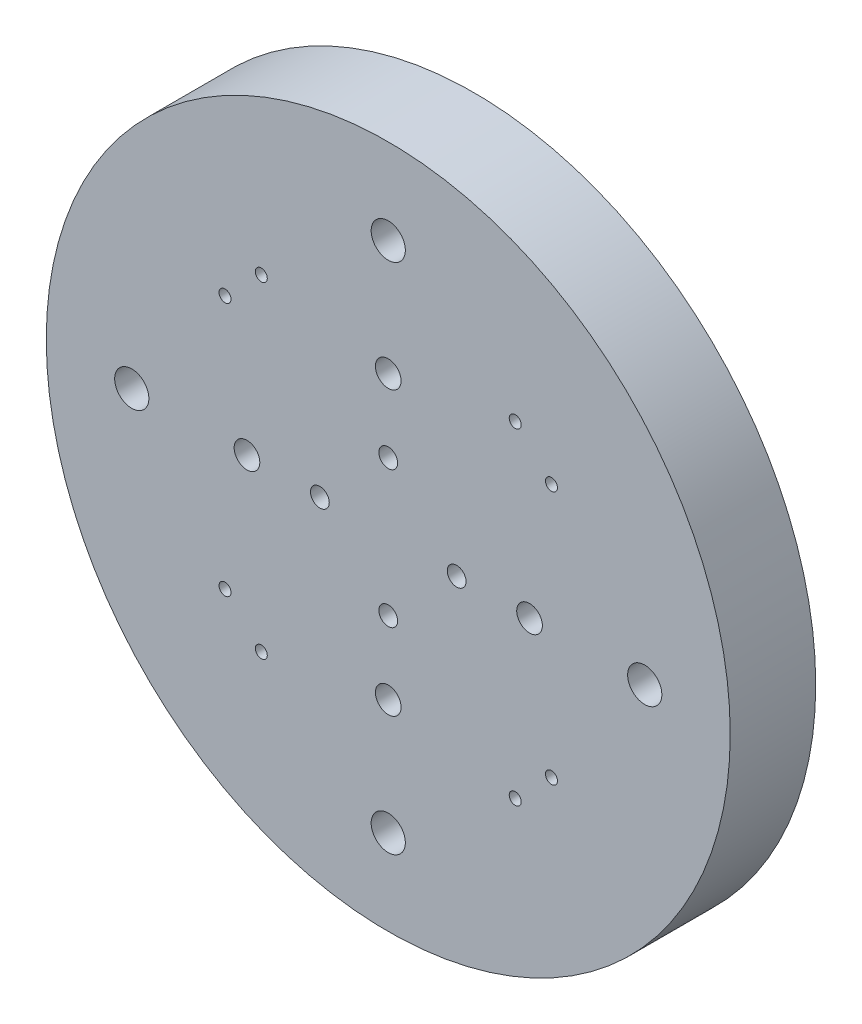
from build123d import *

# Parameters (mm, degrees)
SKETCH1_R                      = 40
BOSS_EXTRUDE1_DEPTH            = 10
F_4_0_4_DIAMETER_HOLE1_D       = 4
F_4_0_4_DIAMETER_HOLE1_DEPTH   = 10
F_4_0_4_DIAMETER_HOLE1_TIP     = 1.201721238
F_2_2_2_2_DIAMETER_HOLE1_D     = 2.2
F_2_2_2_2_DIAMETER_HOLE1_DEPTH = 10
F_2_2_2_2_DIAMETER_HOLE1_TIP   = 0.660946681
F_3_0_3_DIAMETER_HOLE4_D       = 3
F_3_0_3_DIAMETER_HOLE4_DEPTH   = 10
F_3_0_3_DIAMETER_HOLE4_TIP     = 0.901290929
F_1_4_1_4_DIAMETER_HOLE1_D     = 1.4
CIRPATTERN1_COUNT              = 4


with BuildPart() as part:
    # Sketch1 → Boss-Extrude1 (new body)
    with BuildSketch(Plane.XY):
        Circle(SKETCH1_R)
    extrude(amount=BOSS_EXTRUDE1_DEPTH)

    # Ø4.0 (4) Diameter Hole1
    with Locations(Plane.XY.offset(10)):
        with Locations((0, 30), (30, 0), (-30, 0), (0, -30)):
            Hole(F_4_0_4_DIAMETER_HOLE1_D / 2, depth=F_4_0_4_DIAMETER_HOLE1_DEPTH)
            with Locations((0, 0, -(F_4_0_4_DIAMETER_HOLE1_DEPTH + F_4_0_4_DIAMETER_HOLE1_TIP / 2))):  # 118° drill point
                Cone(0, F_4_0_4_DIAMETER_HOLE1_D / 2, F_4_0_4_DIAMETER_HOLE1_TIP, mode=Mode.SUBTRACT)

    # Ø2.2 (2.2) Diameter Hole1
    with Locations(Plane.XY.offset(10)):
        with Locations((0, 8), (0, -8), (-8, 0), (8, 0)):
            Hole(F_2_2_2_2_DIAMETER_HOLE1_D / 2, depth=F_2_2_2_2_DIAMETER_HOLE1_DEPTH)
            with Locations((0, 0, -(F_2_2_2_2_DIAMETER_HOLE1_DEPTH + F_2_2_2_2_DIAMETER_HOLE1_TIP / 2))):  # 118° drill point
                Cone(0, F_2_2_2_2_DIAMETER_HOLE1_D / 2, F_2_2_2_2_DIAMETER_HOLE1_TIP, mode=Mode.SUBTRACT)

    # Ø3.0 (3) Diameter Hole4
    with Locations(Plane.XY.offset(10)):
        with Locations((0, -16.52447999), (16.52447999, 0), (0, 16.52447999), (-16.52447999, 0)):
            Hole(F_3_0_3_DIAMETER_HOLE4_D / 2, depth=F_3_0_3_DIAMETER_HOLE4_DEPTH)
            with Locations((0, 0, -(F_3_0_3_DIAMETER_HOLE4_DEPTH + F_3_0_3_DIAMETER_HOLE4_TIP / 2))):  # 118° drill point
                Cone(0, F_3_0_3_DIAMETER_HOLE4_D / 2, F_3_0_3_DIAMETER_HOLE4_TIP, mode=Mode.SUBTRACT)

    # Ø1.4 (1.4) Diameter Hole1 (through all)
    with Locations(Plane.XY.offset(10)):
        with Locations((-14.849242405, -19.091883092), (-19.091883092, -14.849242405)):
            f_1_4_1_4_diameter_hole1 = Hole(F_1_4_1_4_DIAMETER_HOLE1_D / 2)

    # CirPattern1: Ø1.4 (1.4) Diameter Hole1 ×4 about axis
    cirpattern1_axis = Axis((0, 0, 0), (0, 0, 1))
    for i in range(1, CIRPATTERN1_COUNT):
        add(f_1_4_1_4_diameter_hole1.rotate(cirpattern1_axis, i * 360 / CIRPATTERN1_COUNT), mode=Mode.SUBTRACT)


solid = part.part
